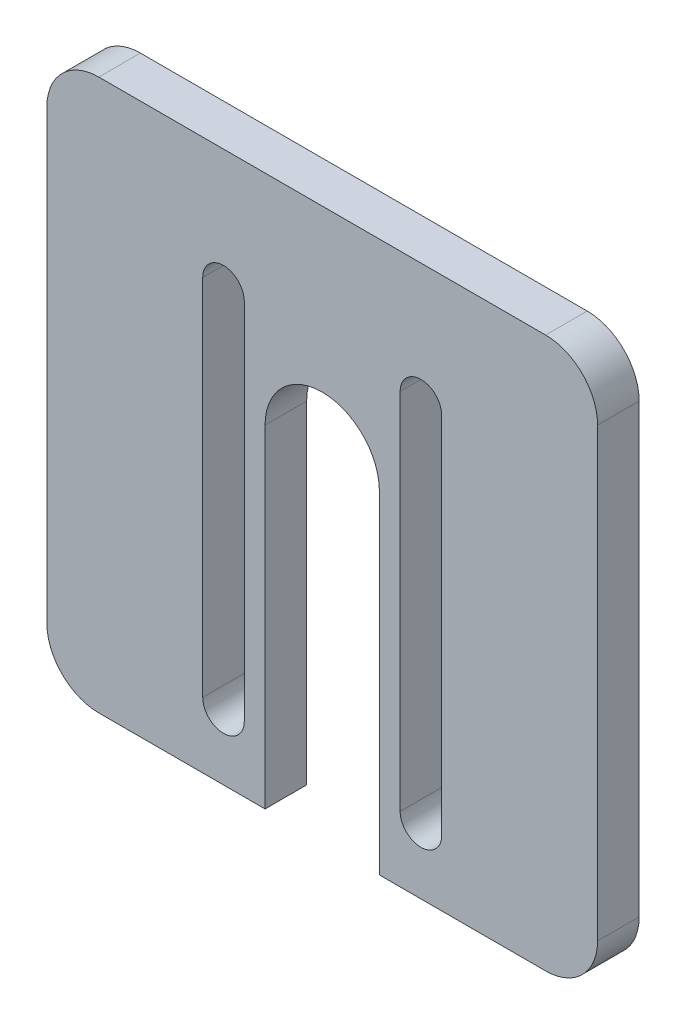
from build123d import *

# Parameters (mm, degrees)
BOSS_EXTRUDE2_DEPTH = 4


with BuildPart() as part:
    # Sketch1 → Boss-Extrude2 (new body)
    with BuildSketch(Plane.XY):
        with BuildLine():
            Line((0, 48), (0, 5))
            ThreePointArc((0, 5), (1.464466094, 1.464466094), (5, 0))
            Line((5, 0), (21, 0))
            Line((21, 0), (21, 31.99499657))
            ThreePointArc((21, 31.99499657), (26.5, 37.49499657), (32, 31.99499657))
            Line((32, 31.99499657), (32, 0))
            Line((32, 0), (48, 0))
            ThreePointArc((48, 0), (51.535533906, 1.464466094), (53, 5))
            Line((53, 5), (53, 48))
            ThreePointArc((53, 48), (51.535533906, 51.535533906), (48, 53))
            Line((48, 53), (5, 53))
            ThreePointArc((5, 53), (1.464466094, 51.535533906), (0, 48))
        make_face()
        with BuildLine():
            Line((19, 41.300206215), (19, 6.300206215))
            ThreePointArc((19, 6.300206215), (17, 4.300206215), (15, 6.300206215))
            Line((15, 6.300206215), (15, 41.300206215))
            ThreePointArc((15, 41.300206215), (17, 43.300206215), (19, 41.300206215))
        make_face(mode=Mode.SUBTRACT)
        with BuildLine():
            Line((38, 41.300206215), (38, 6.300206215))
            ThreePointArc((38, 6.300206215), (36, 4.300206215), (34, 6.300206215))
            Line((34, 6.300206215), (34, 41.300206215))
            ThreePointArc((34, 41.300206215), (36, 43.300206215), (38, 41.300206215))
        make_face(mode=Mode.SUBTRACT)
    extrude(amount=BOSS_EXTRUDE2_DEPTH)


solid = part.part
